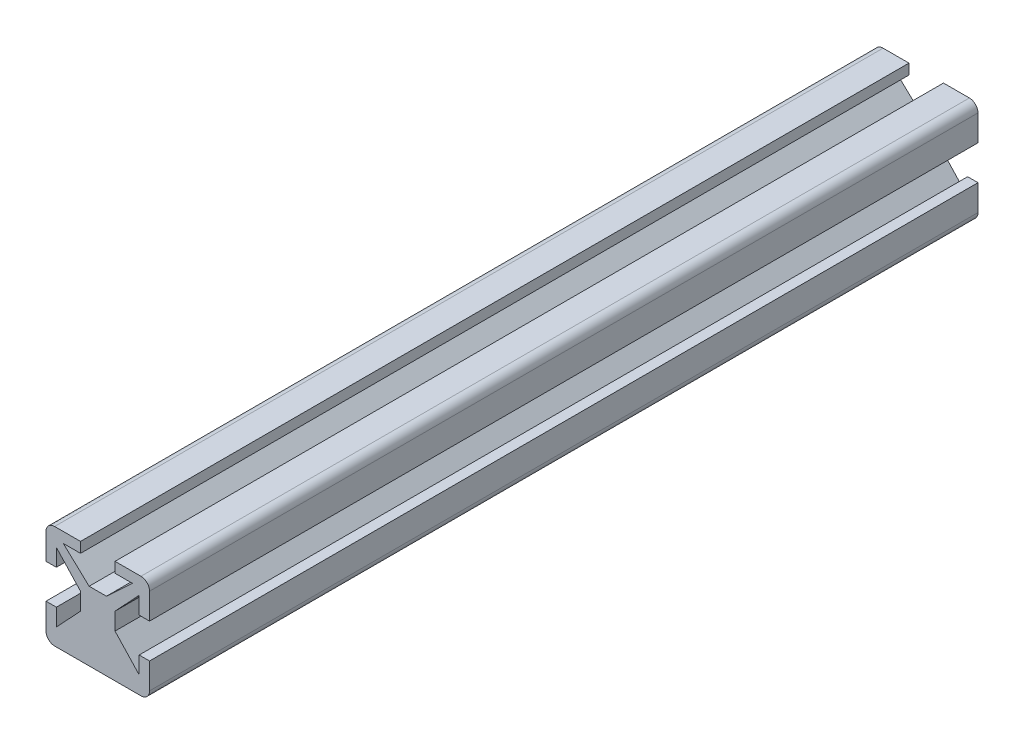
from build123d import *

# Parameters (mm, degrees)
EXTRUSION1_DEPTH             = 48
ENL_V_MAT_EXTRU_1_DEPTH      = 97.374270425
R_P_TITION_CIRCULAIRE1_COUNT = 3
R_P_TITION_CIRCULAIRE1_ANGLE = 180


with BuildPart() as part:
    # Esquisse1 → Extrusion1 (new, symmetric)
    with BuildSketch(Plane.XY):
        with BuildLine():
            Line((-6, 5), (-6, -5))
            ThreePointArc((-6, -5), (-5.707106781, -5.707106781), (-5, -6))
            Line((-5, -6), (5, -6))
            ThreePointArc((5, -6), (5.707106781, -5.707106781), (6, -5))
            Line((6, -5), (6, 5))
            ThreePointArc((6, 5), (5.707106781, 5.707106781), (5, 6))
            Line((5, 6), (-5, 6))
            ThreePointArc((-5, 6), (-5.707106781, 5.707106781), (-6, 5))
        make_face()
    extrude(amount=EXTRUSION1_DEPTH, both=True)

    # Esquisse3 → Enlèv. mat.-Extru.1 (cut, through all)
    with BuildSketch(Plane.XY.offset(48)):
        Polygon((6, 2), (4.8, 2), (4.8, 4), (2, 1), (2, -1), (4.8, -4), (4.8, -2), (6, -2), align=None)
    enl_v_mat_extru_1 = extrude(amount=-ENL_V_MAT_EXTRU_1_DEPTH, mode=Mode.SUBTRACT)

    # Répétition circulaire1: Enlèv. mat.-Extru.1 ×3 about axis
    r_p_tition_circulaire1_axis = Axis((0, 0, -1), (0, 0, 1))
    for i in range(1, R_P_TITION_CIRCULAIRE1_COUNT):
        add(enl_v_mat_extru_1.rotate(r_p_tition_circulaire1_axis, i * R_P_TITION_CIRCULAIRE1_ANGLE / (R_P_TITION_CIRCULAIRE1_COUNT - 1)), mode=Mode.SUBTRACT)


solid = part.part
